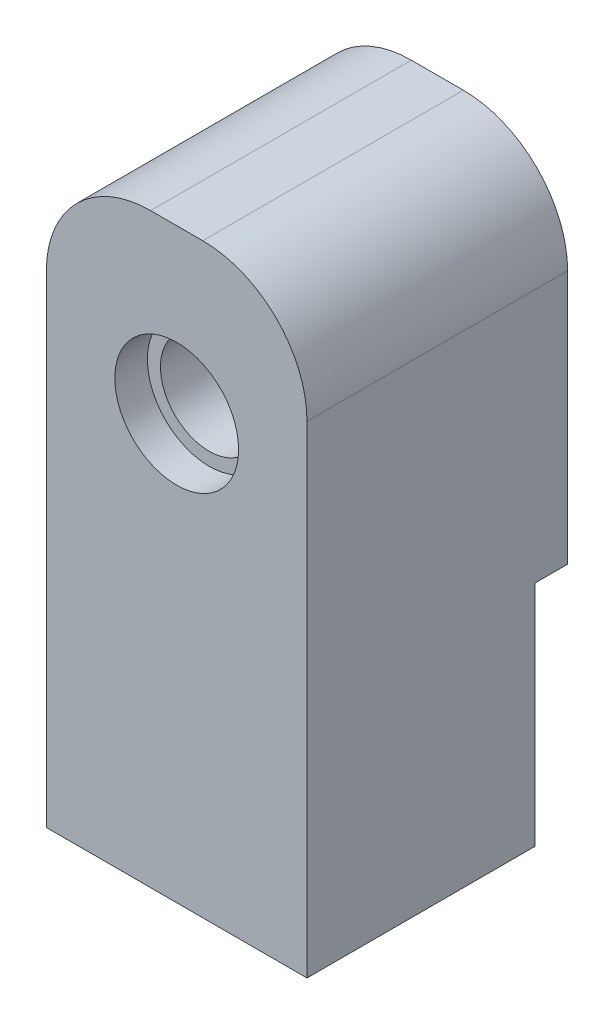
from build123d import *

# Parameters (mm, degrees)
BOSS_EXTRUDE1_DEPTH = 12.7
SKETCH2_R           = 6.0325
CUT_EXTRUDE1_DEPTH  = 3.175
SKETCH3_R           = 4.7625
CUT_EXTRUDE2_DEPTH  = 23.225
FILLET1_R           = 10.16
SKETCH4_R           = 6.35
CUT_EXTRUDE3_DEPTH  = 30.1752


with BuildPart() as part:
    # Sketch1 → Boss-Extrude1 (new body, symmetric)
    with BuildSketch(Plane(origin=(0, 0, 0), x_dir=(0, 0, -1), z_dir=(1, 0, 0))):
        Polygon((-16.575791508, 0), (-16.575791508, 57.15), (8.824208492, 57.15), (8.824208492, 22.225), (5.649208492, 22.225), (5.649208492, 0), align=None)
    extrude(amount=BOSS_EXTRUDE1_DEPTH, both=True)

    # Sketch2 → Cut-Extrude1 (cut)
    with BuildSketch(Plane.XY.offset(16.575791508)):
        with Locations((0, 41.275)):
            Circle(SKETCH2_R)
    extrude(amount=-CUT_EXTRUDE1_DEPTH, mode=Mode.SUBTRACT)

    # Sketch3 → Cut-Extrude2 (cut, through all)
    with BuildSketch(Plane.XY.offset(13.400791508)):
        with Locations((0, 41.275)):
            Circle(SKETCH3_R)
    extrude(amount=-CUT_EXTRUDE2_DEPTH, mode=Mode.SUBTRACT)

    # Fillet1
    fillet1_edges = [part.edges().sort_by_distance(p)[0] for p in [
        (12.7, 57.15, 3.875791508),
        (-12.7, 57.15, 3.875791508),
    ]]
    fillet(fillet1_edges, radius=FILLET1_R)

    # Sketch4 → Cut-Extrude3 (cut)
    with BuildSketch(Plane.XZ):
        with Locations((0, 3.875791508)):
            Circle(SKETCH4_R)
    extrude(amount=-CUT_EXTRUDE3_DEPTH, mode=Mode.SUBTRACT)


solid = part.part
